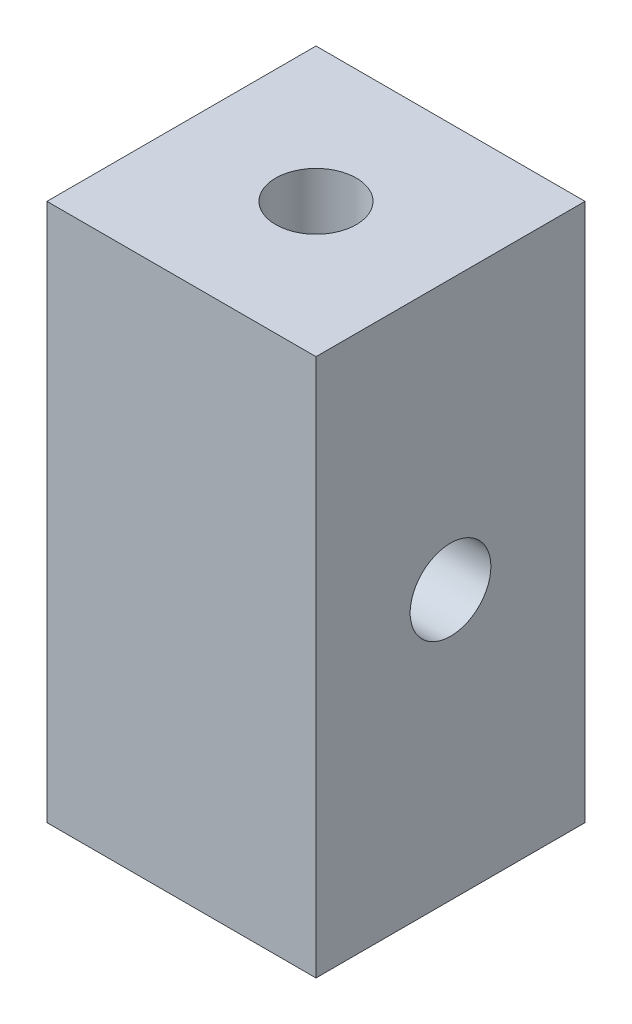
from build123d import *

# Parameters (mm, degrees)
SKETCH1_W           = 10
SKETCH1_H           = 10
BOSS_EXTRUDE1_DEPTH = 20
SKETCH4_R           = 1.5
CUT_EXTRUDE2_DEPTH  = 11
SKETCH5_R           = 1.5
CUT_EXTRUDE3_DEPTH  = 21


with BuildPart() as part:
    # Sketch1 → Boss-Extrude1 (new body)
    with BuildSketch(Plane(origin=(0, 0, 0), x_dir=(1, 0, 0), z_dir=(0, 1, 0))):
        Rectangle(SKETCH1_W, SKETCH1_H)
    extrude(amount=BOSS_EXTRUDE1_DEPTH)

    # Sketch4 → Cut-Extrude2 (cut, through all)
    with BuildSketch(Plane(origin=(5, 0, 0), x_dir=(0, 0, -1), z_dir=(1, 0, 0))):
        with Locations((0, 10)):
            Circle(SKETCH4_R)
    extrude(amount=-CUT_EXTRUDE2_DEPTH, mode=Mode.SUBTRACT)

    # Sketch5 → Cut-Extrude3 (cut, through all)
    with BuildSketch(Plane(origin=(0, 20, 0), x_dir=(1, 0, 0), z_dir=(0, 1, 0))):
        Circle(SKETCH5_R)
    extrude(amount=-CUT_EXTRUDE3_DEPTH, mode=Mode.SUBTRACT)


solid = part.part
